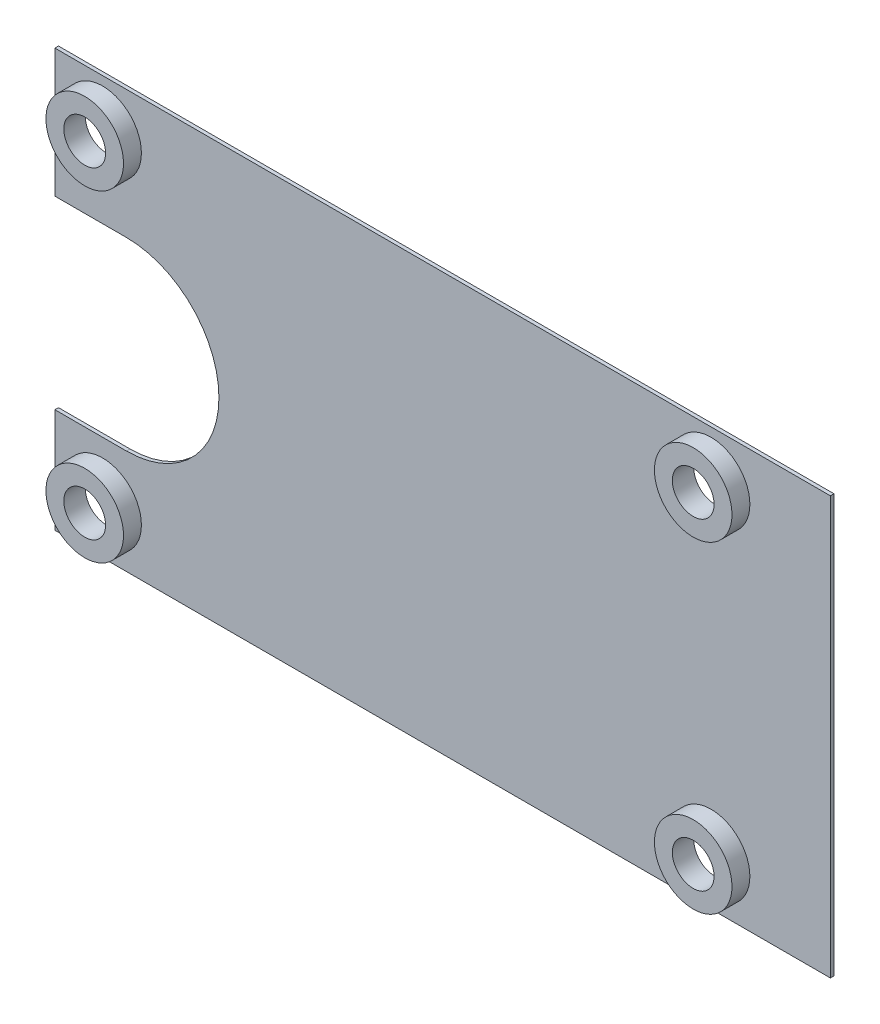
from build123d import *

# Parameters (mm, degrees)
SKETCH2_W           = 65
SKETCH2_H           = 35
BOSS_EXTRUDE1_DEPTH = 0.3
SKETCH3_R           = 1.75
CUT_EXTRUDE1_DEPTH  = 1.6
SKETCH4_R           = 3.25
SKETCH4_R_2         = 1.75
BOSS_EXTRUDE2_DEPTH = 1.5
CUT_EXTRUDE2_DEPTH  = 10


with BuildPart() as part:
    # Sketch2 → Boss-Extrude1 (new body)
    with BuildSketch(Plane.XY):
        Rectangle(SKETCH2_W, SKETCH2_H)
    extrude(amount=BOSS_EXTRUDE1_DEPTH)

    # Sketch3 → Cut-Extrude1 (cut)
    with BuildSketch(Plane.XY.offset(0.3)):
        with Locations((-28.5, 13.5)):
            Circle(SKETCH3_R)
        with Locations((-28.5, -13.5)):
            Circle(SKETCH3_R)
        with Locations((22.5, 13.5)):
            Circle(SKETCH3_R)
        with Locations((22.5, -13.5)):
            Circle(SKETCH3_R)
    extrude(amount=-CUT_EXTRUDE1_DEPTH, mode=Mode.SUBTRACT)

    # Sketch4 → Boss-Extrude2 (add)
    with BuildSketch(Plane.XY.offset(0.3)):
        with Locations((-28.5, 13.5)):
            Circle(SKETCH4_R)
        with Locations((-28.5, 13.5)):
            Circle(SKETCH4_R_2, mode=Mode.SUBTRACT)
        with Locations((-28.5, -13.5)):
            Circle(SKETCH4_R)
        with Locations((-28.5, -13.5)):
            Circle(SKETCH4_R_2, mode=Mode.SUBTRACT)
        with Locations((22.5, -13.5)):
            Circle(SKETCH4_R)
        with Locations((22.5, -13.5)):
            Circle(SKETCH4_R_2, mode=Mode.SUBTRACT)
        with Locations((22.5, 13.5)):
            Circle(SKETCH4_R)
        with Locations((22.5, 13.5)):
            Circle(SKETCH4_R_2, mode=Mode.SUBTRACT)
    extrude(amount=BOSS_EXTRUDE2_DEPTH)

    # Sketch5 → Cut-Extrude2 (cut)
    with BuildSketch(Plane.XY.offset(0.3)):
        with BuildLine():
            Line((-32.5, 6.75), (-26.5, 6.75))
            ThreePointArc((-26.5, 6.75), (-18.75, -1), (-26.5, -8.75))
            Line((-26.5, -8.75), (-32.5, -8.75))
            ThreePointArc((-32.5, -8.75), (-40.25, -1), (-32.5, 6.75))
        make_face()
    extrude(amount=-CUT_EXTRUDE2_DEPTH, mode=Mode.SUBTRACT)


solid = part.part
